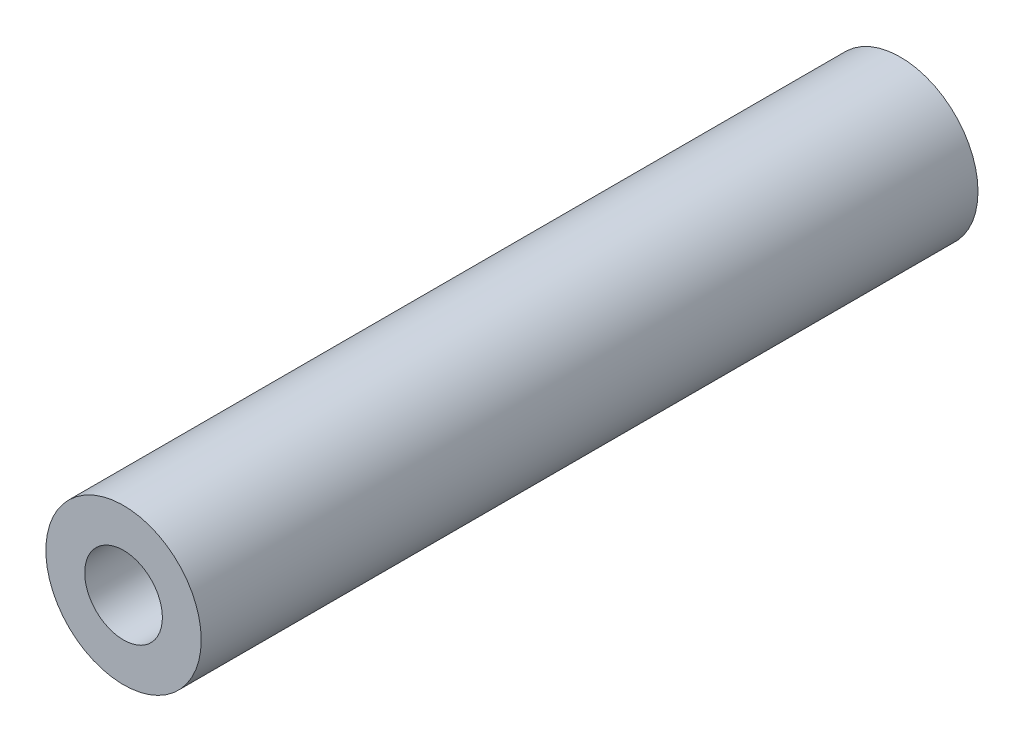
from build123d import *

# Parameters (mm, degrees)
SCHIZZO1_R                   = 2
SCHIZZO1_R_2                 = 1
ESTRUSIONE_ESTRUSIONE1_DEPTH = 20


with BuildPart() as part:
    # Schizzo1 → Estrusione-Estrusione1 (new body)
    with BuildSketch(Plane.XY):
        Circle(SCHIZZO1_R)
        Circle(SCHIZZO1_R_2, mode=Mode.SUBTRACT)
    extrude(amount=ESTRUSIONE_ESTRUSIONE1_DEPTH)


solid = part.part
